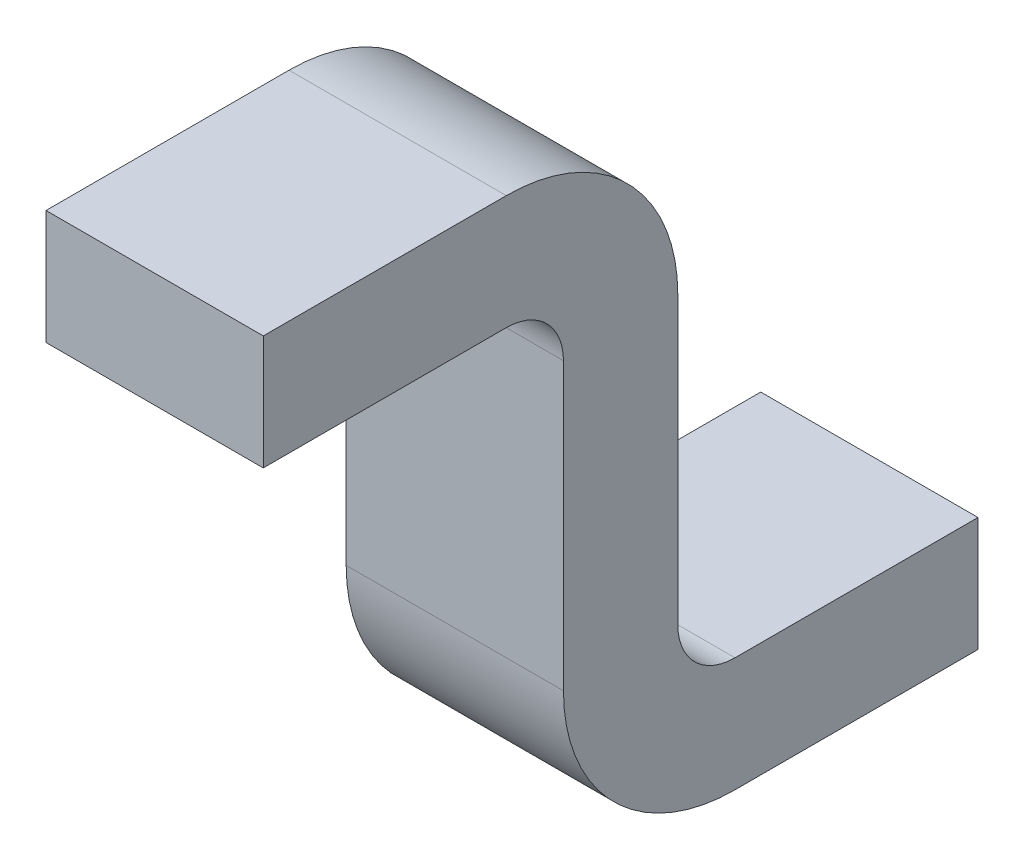
from build123d import *

# Parameters (mm, degrees)
EXTRUDE1_DEPTH = 0.38


with BuildPart() as part:
    # Sketch2 → Extrude1 (new body)
    with BuildSketch(Plane(origin=(0, 0, 0), x_dir=(0, 0, -1), z_dir=(1, 0, 0))):
        with BuildLine():
            Line((0, 0.9), (0.425, 0.9))
            ThreePointArc((0.425, 0.9), (0.495710678, 0.870710678), (0.525, 0.8))
            Line((0.525, 0.8), (0.525, 0.3))
            ThreePointArc((0.525, 0.3), (0.612867966, 0.087867966), (0.825, 0))
            Line((0.825, 0), (1.25, 0))
            Line((1.25, 0), (1.25, 0.2))
            Line((1.25, 0.2), (0.825, 0.2))
            ThreePointArc((0.825, 0.2), (0.754289322, 0.229289322), (0.725, 0.3))
            Line((0.725, 0.3), (0.725, 0.8))
            ThreePointArc((0.725, 0.8), (0.637132034, 1.012132034), (0.425, 1.1))
            Line((0.425, 1.1), (0, 1.1))
            Line((0, 1.1), (0, 0.9))
        make_face()
    extrude(amount=EXTRUDE1_DEPTH)


solid = part.part
